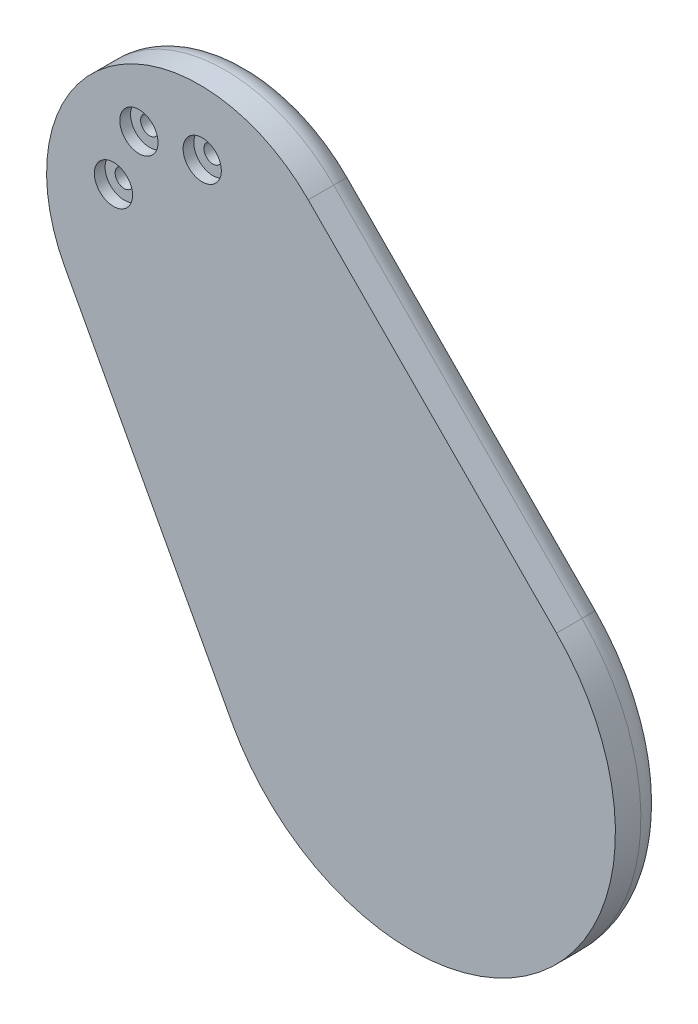
from build123d import *

# Parameters (mm, degrees)
SKETCH3_R                                           = 6.35
BOSS_EXTRUDE2_DEPTH                                 = 5.08
BOSS_EXTRUDE2_DEPTH_BACK                            = 9.525
BOSS_EXTRUDE3_DEPTH                                 = 12.7
SKETCH5_R                                           = 3.175
BOSS_EXTRUDE4_DEPTH                                 = 10.16
SKETCH6_R                                           = 13.88872
SKETCH6_R_2                                         = 6.35
BOSS_EXTRUDE5_DEPTH                                 = 8.255
SKETCH7_R                                           = 7.63778
SKETCH7_R_2                                         = 3.175
BOSS_EXTRUDE6_DEPTH                                 = 5.1816
FILLET3_R                                           = 6.35
FILLET4_R                                           = 2.54
FILLET1_R                                           = 0.635
FILLET5_R                                           = 0.254
CBORE_FOR_8_BINDING_HEAD_MACHINE_SCREW1_D           = 4.4958
CBORE_FOR_8_BINDING_HEAD_MACHINE_SCREW1_DEPTH       = 12.7
CBORE_FOR_8_BINDING_HEAD_MACHINE_SCREW1_CBORE_D     = 9.525
CBORE_FOR_8_BINDING_HEAD_MACHINE_SCREW1_CBORE_DEPTH = 2.667
CBORE_FOR_8_BINDING_HEAD_MACHINE_SCREW1_TIP         = 1.350674586


with BuildPart() as part:
    # Sketch3 → Boss-Extrude2 (new body, two sides)
    with BuildSketch(Plane.XY.offset(-6.35)) as boss_extrude2_sk:
        Circle(SKETCH3_R)
    extrude(amount=BOSS_EXTRUDE2_DEPTH)
    extrude(boss_extrude2_sk.sketch, amount=-BOSS_EXTRUDE2_DEPTH_BACK)

    # Sketch4 → Boss-Extrude3 (add)
    with BuildSketch(Plane.XY.offset(-1.27)):
        with BuildLine():
            Line((-44.750067041, -24.043117516), (-86.39396815, 53.466272241))
            ThreePointArc((-86.39396815, 53.466272241), (-75.473454099, 102.140871968), (-25.738020798, 98.285880397))
            Line((-25.738020798, 98.285880397), (36.124529429, 35.716360026))
            ThreePointArc((36.124529429, 35.716360026), (30.18938164, -40.856348787), (-44.750067041, -24.043117516))
        make_face()
    extrude(amount=BOSS_EXTRUDE3_DEPTH)

    # Sketch5 → Boss-Extrude4 (add)
    with BuildSketch(Plane(origin=(0, 0, -1.27), x_dir=(-1, 0, 0), z_dir=(0, 0, -1))):
        with Locations((52.831417869, 71.498610377)):
            Circle(SKETCH5_R)
    extrude(amount=BOSS_EXTRUDE4_DEPTH)

    # Sketch6 → Boss-Extrude5 (add)
    with BuildSketch(Plane(origin=(0, 0, -1.27), x_dir=(-1, 0, 0), z_dir=(0, 0, -1))):
        Circle(SKETCH6_R)
        Circle(SKETCH6_R_2, mode=Mode.SUBTRACT)
    extrude(amount=BOSS_EXTRUDE5_DEPTH)

    # Sketch7 → Boss-Extrude6 (add)
    with BuildSketch(Plane(origin=(0, 0, -1.27), x_dir=(-1, 0, 0), z_dir=(0, 0, -1))):
        with Locations((52.831417869, 71.498610377)):
            Circle(SKETCH7_R)
        with Locations((52.831417869, 71.498610377)):
            Circle(SKETCH7_R_2, mode=Mode.SUBTRACT)
    extrude(amount=BOSS_EXTRUDE6_DEPTH)

    # Fillet3
    fillet3_edges = [part.edges().sort_by_distance(p)[0] for p in [
        (30.18938164, -40.856348787, -1.27),
        (5.193254316, 67.001120212, -1.27),
        (-75.473454099, 102.140871968, -1.27),
        (-65.572017595, 14.711577363, -1.27),
    ]]
    fillet(fillet3_edges, radius=FILLET3_R)

    # Fillet4
    fillet4_edges = [part.edges().sort_by_distance(p)[0] for p in [
        (13.88872, 0, -1.27),
        (-45.193637869, 71.498610377, -1.27),
    ]]
    fillet(fillet4_edges, radius=FILLET4_R)

    # Fillet1
    fillet1_edges = [part.edges().sort_by_distance(p)[0] for p in [
        (-49.656417869, 71.498610377, -11.43),
        (-6.35, 0, -15.875),
    ]]
    fillet(fillet1_edges, radius=FILLET1_R)

    # Fillet5
    fillet5_edges = [part.edges().sort_by_distance(p)[0] for p in [
        (13.88872, 0, -9.525),
        (-45.193637869, 71.498610377, -6.4516),
    ]]
    fillet(fillet5_edges, radius=FILLET5_R)

    # CBORE for #8 Binding Head Machine Screw1
    with Locations(Plane.XY.offset(11.43)):
        with Locations((-52.151944072, 93.713221343), (-67.926108689, 91.926784771), (-74.266091544, 77.372739203)):
            CounterBoreHole(CBORE_FOR_8_BINDING_HEAD_MACHINE_SCREW1_D / 2, CBORE_FOR_8_BINDING_HEAD_MACHINE_SCREW1_CBORE_D / 2, CBORE_FOR_8_BINDING_HEAD_MACHINE_SCREW1_CBORE_DEPTH, depth=CBORE_FOR_8_BINDING_HEAD_MACHINE_SCREW1_DEPTH)
            with Locations((0, 0, -(CBORE_FOR_8_BINDING_HEAD_MACHINE_SCREW1_DEPTH + CBORE_FOR_8_BINDING_HEAD_MACHINE_SCREW1_TIP / 2))):  # 118° drill point
                Cone(0, CBORE_FOR_8_BINDING_HEAD_MACHINE_SCREW1_D / 2, CBORE_FOR_8_BINDING_HEAD_MACHINE_SCREW1_TIP, mode=Mode.SUBTRACT)


solid = part.part
